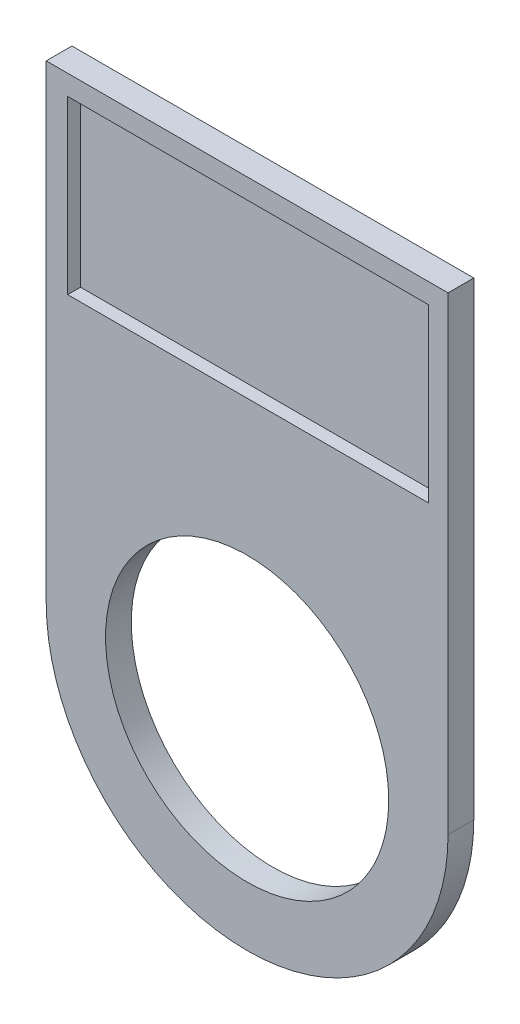
from build123d import *

# Parameters (mm, degrees)
SKETCH1_R           = 11
SKETCH1_W           = 28.025444105
SKETCH1_H           = 13.338271477
BOSS_EXTRUDE1_DEPTH = 2
SKETCH2_W           = 28.025444105
SKETCH2_H           = 13.338271477
BOSS_EXTRUDE2_DEPTH = 1


with BuildPart() as part:
    # Sketch1 → Boss-Extrude1 (new body)
    with BuildSketch(Plane.XY):
        with BuildLine():
            Line((420.808310711, 971.794452341), (420.808310711, 1008.244630448))
            Line((420.808310711, 1008.244630448), (452.024309123, 1008.244630448))
            Line((452.024309123, 1008.244630448), (452.024309123, 971.794452341))
            ThreePointArc((452.024309123, 971.794452341), (436.416309917, 956.186453136), (420.808310711, 971.794452341))
        make_face()
        with Locations((436.416309917, 971.794452341)):
            Circle(SKETCH1_R, mode=Mode.SUBTRACT)
        with Locations((436.489180342, 1000.019726734)):
            Rectangle(SKETCH1_W, SKETCH1_H, mode=Mode.SUBTRACT)
    extrude(amount=BOSS_EXTRUDE1_DEPTH)

    # Sketch2 → Boss-Extrude2 (add)
    with BuildSketch(Plane.XY):
        with Locations((436.489180342, 1000.019726734)):
            Rectangle(SKETCH2_W, SKETCH2_H)
    extrude(amount=BOSS_EXTRUDE2_DEPTH)


solid = part.part
